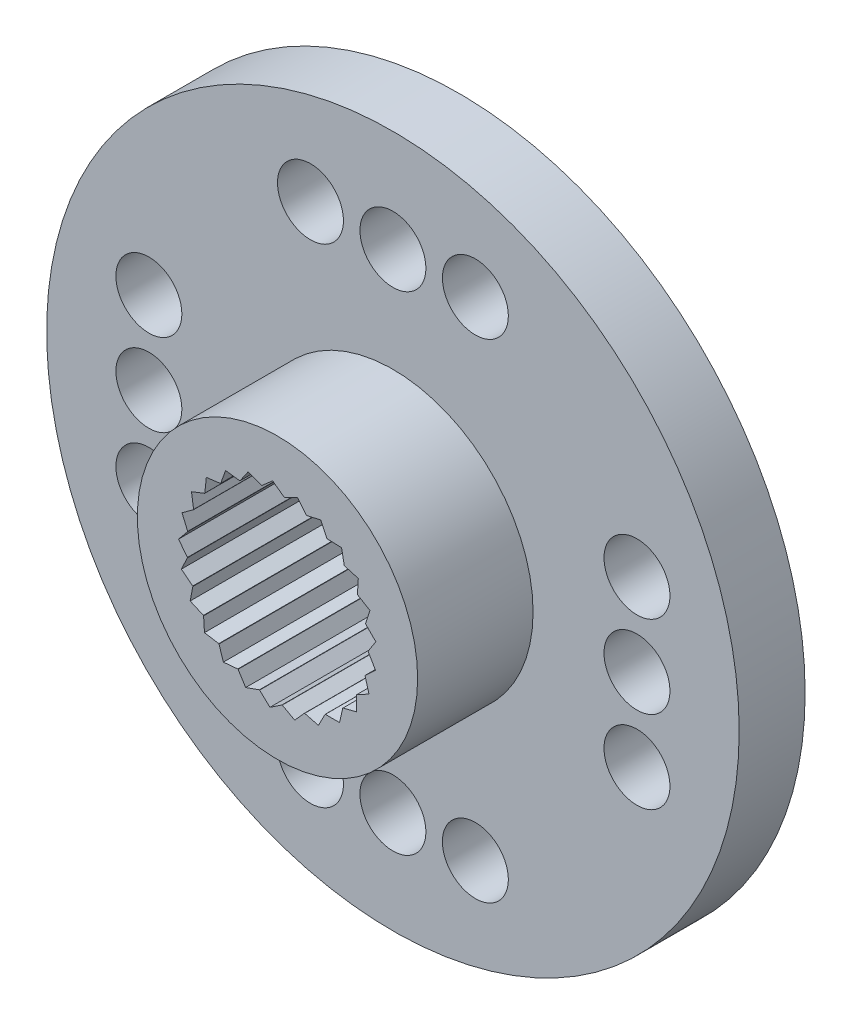
from build123d import *

# Parameters (mm, degrees)
SKETCH1_R           = 10.5
BOSS_EXTRUDE1_DEPTH = 2
SKETCH2_R           = 4.25
BOSS_EXTRUDE2_DEPTH = 3.5
SKETCH3_R           = 2.75
CUT_EXTRUDE1_DEPTH  = 4.5
SKETCH4_R           = 1.6
CUT_EXTRUDE2_DEPTH  = 3.5
SKETCH5_R           = 1
CUT_EXTRUDE3_DEPTH  = 3.5
CUT_EXTRUDE4_DEPTH  = 4.5
CIRPATTERN1_COUNT   = 25


with BuildPart() as part:
    # Sketch1 → Boss-Extrude1 (new body)
    with BuildSketch(Plane.XY):
        Circle(SKETCH1_R)
    extrude(amount=BOSS_EXTRUDE1_DEPTH)

    # Sketch2 → Boss-Extrude2 (add)
    with BuildSketch(Plane.XY.offset(2)):
        Circle(SKETCH2_R)
    extrude(amount=BOSS_EXTRUDE2_DEPTH)

    # Sketch3 → Cut-Extrude1 (cut)
    with BuildSketch(Plane.XY.offset(5.5)):
        Circle(SKETCH3_R)
    extrude(amount=-CUT_EXTRUDE1_DEPTH, mode=Mode.SUBTRACT)

    # Sketch4 → Cut-Extrude2 (cut)
    with BuildSketch(Plane.XY):
        Circle(SKETCH4_R)
    extrude(amount=CUT_EXTRUDE2_DEPTH, mode=Mode.SUBTRACT)

    # Sketch5 → Cut-Extrude3 (cut)
    with BuildSketch(Plane.XY.offset(2)):
        with Locations((0, 7.4)):
            Circle(SKETCH5_R)
        with Locations((-2.5, 7.4)):
            Circle(SKETCH5_R)
        with Locations((2.5, 7.4)):
            Circle(SKETCH5_R)
        with Locations((2.5, -7.4)):
            Circle(SKETCH5_R)
        with Locations((-2.5, -7.4)):
            Circle(SKETCH5_R)
        with Locations((0, -7.4)):
            Circle(SKETCH5_R)
        with Locations((7.4, 0)):
            Circle(SKETCH5_R)
        with Locations((7.4, 2.5)):
            Circle(SKETCH5_R)
        with Locations((7.4, -2.5)):
            Circle(SKETCH5_R)
        with Locations((-7.4, -2.5)):
            Circle(SKETCH5_R)
        with Locations((-7.4, 2.5)):
            Circle(SKETCH5_R)
        with Locations((-7.4, 0)):
            Circle(SKETCH5_R)
    extrude(amount=-CUT_EXTRUDE3_DEPTH, mode=Mode.SUBTRACT)

    # Sketch6 → Cut-Extrude4 (cut)
    with BuildSketch(Plane.XY.offset(5.5)):
        with BuildLine():
            Line((-2.895429002, 0.78516934), (-2.654143252, 0.719738562))
            ThreePointArc((-2.654143252, 0.719738562), (-2.605253752, 0.880427673), (-2.546645605, 1.037832435))
            Line((-2.546645605, 1.037832435), (-2.895429002, 0.78516934))
        make_face()
        with BuildLine():
            Line((-2.895429002, 0.78516934), (-2.723421701, 0.381410852))
            ThreePointArc((-2.723421701, 0.381410852), (-2.694098665, 0.551663288), (-2.654143252, 0.719738562))
            Line((-2.654143252, 0.719738562), (-2.895429002, 0.78516934))
        make_face()
    cut_extrude4 = extrude(amount=-CUT_EXTRUDE4_DEPTH, mode=Mode.SUBTRACT)

    # CirPattern1: Cut-Extrude4 ×25 about axis
    cirpattern1_axis = Axis((0, 0, 0), (0, 0, 1))
    for i in range(1, CIRPATTERN1_COUNT):
        add(cut_extrude4.rotate(cirpattern1_axis, i * 360 / CIRPATTERN1_COUNT), mode=Mode.SUBTRACT)


solid = part.part
